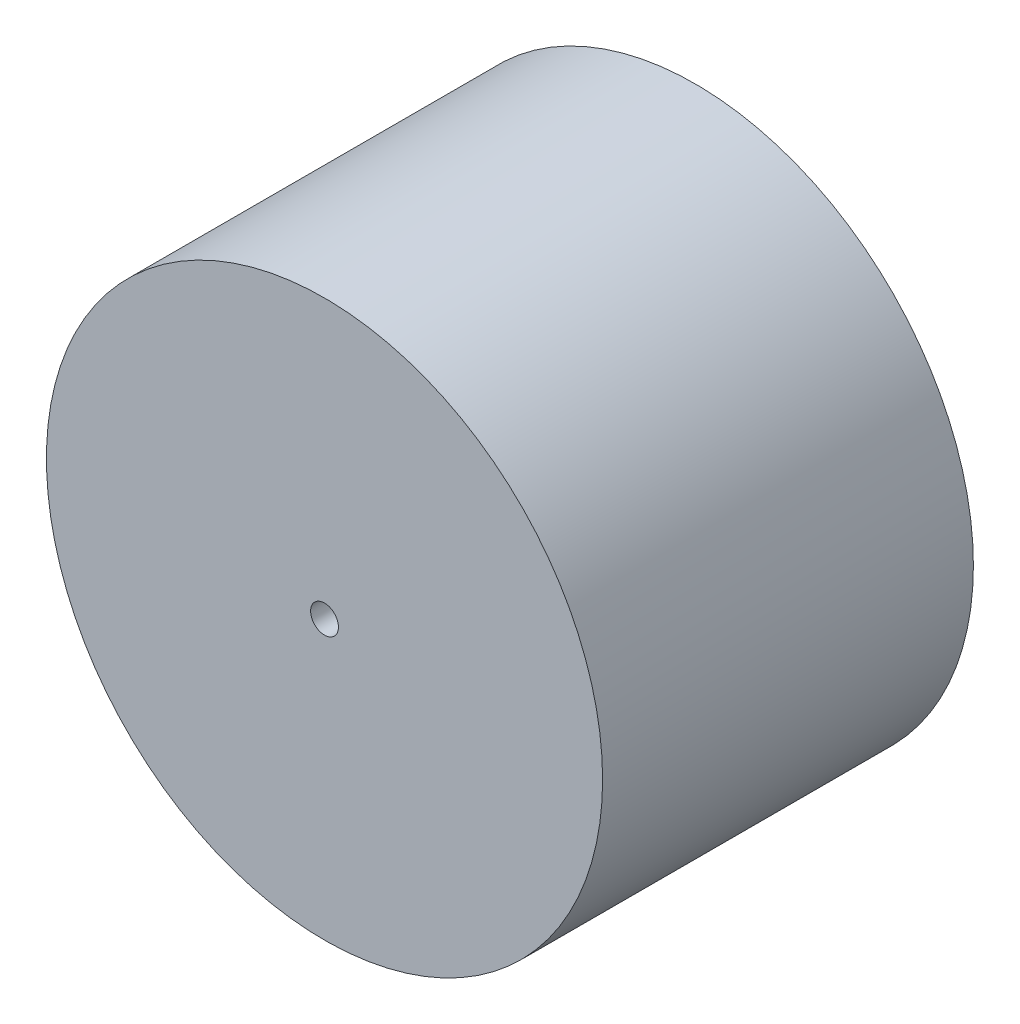
from build123d import *

# Parameters (mm, degrees)
SKETCH1_R           = 30
BOSS_EXTRUDE1_DEPTH = 40
SKETCH2_R           = 20
CUT_EXTRUDE1_DEPTH  = 25
CUT_EXTRUDE2_DEPTH  = 5
SKETCH5_R           = 1.5
CUT_EXTRUDE3_DEPTH  = 40


with BuildPart() as part:
    # Sketch1 → Boss-Extrude1 (new body)
    with BuildSketch(Plane.XY):
        Circle(SKETCH1_R)
    extrude(amount=BOSS_EXTRUDE1_DEPTH)

    # Sketch2 → Cut-Extrude1 (cut)
    with BuildSketch(Plane(origin=(0, 0, 0), x_dir=(-1, 0, 0), z_dir=(0, 0, -1))):
        Circle(SKETCH2_R)
    extrude(amount=-CUT_EXTRUDE1_DEPTH, mode=Mode.SUBTRACT)

    # Sketch3 → Cut-Extrude2 (cut)
    with BuildSketch(Plane(origin=(0, 0, 25), x_dir=(-1, 0, 0), z_dir=(0, 0, -1))):
        Polygon((4.082774554, -4.396697846), (5.849039304, 1.337437558), (1.76626475, 5.734135404), (-4.082774554, 4.396697846), (-5.849039304, -1.337437558), (-1.76626475, -5.734135404), align=None)
    extrude(amount=-CUT_EXTRUDE2_DEPTH, mode=Mode.SUBTRACT)

    # Sketch5 → Cut-Extrude3 (cut)
    with BuildSketch(Plane.XY.offset(40)):
        Circle(SKETCH5_R)
    extrude(amount=-CUT_EXTRUDE3_DEPTH, mode=Mode.SUBTRACT)


solid = part.part
